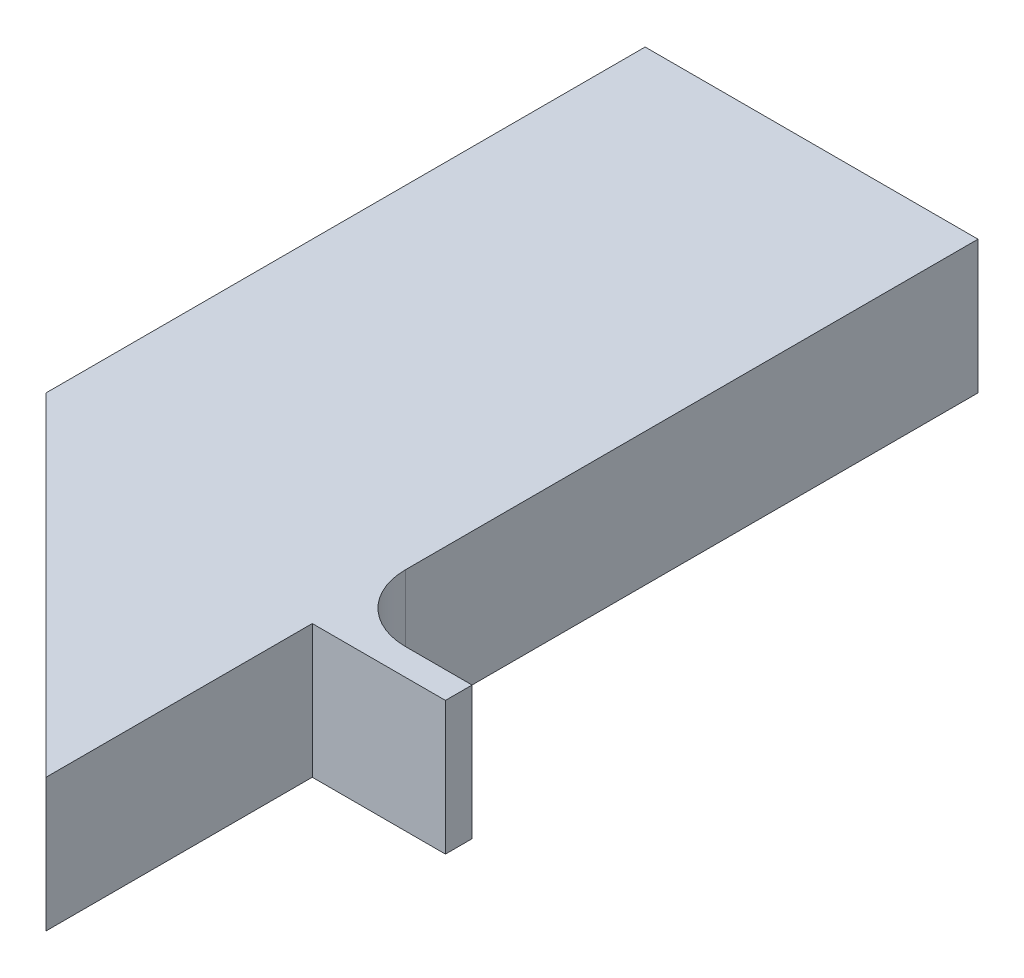
from build123d import *

# Parameters (mm, degrees)
BOSS_EXTRUDE1_DEPTH = 20
SKETCH2_W           = 4
SKETCH2_H           = 20
BOSS_EXTRUDE2_DEPTH = 20
SKETCH3_W           = 46
SKETCH3_H           = 12
CUT_EXTRUDE1_DEPTH  = 46
SKETCH4_R           = 11
CUT_EXTRUDE2_DEPTH  = 8
FILLET1_R           = 10


with BuildPart() as part:
    # Sketch1 → Boss-Extrude1 (new body)
    with BuildSketch(Plane(origin=(0, 0, 0), x_dir=(1, 0, 0), z_dir=(0, 1, 0))):
        Polygon((-50, 50), (0, 0), (0, 140), (-50, 140), align=None)
    extrude(amount=BOSS_EXTRUDE1_DEPTH)

    # Sketch2 → Boss-Extrude2 (add)
    with BuildSketch(Plane(origin=(0, 0, 0), x_dir=(0, 0, -1), z_dir=(1, 0, 0))):
        with Locations((42, 10)):
            Rectangle(SKETCH2_W, SKETCH2_H)
    extrude(amount=BOSS_EXTRUDE2_DEPTH)

    # Sketch3 → Cut-Extrude1 (cut)
    with BuildSketch(Plane.ZY.offset(50)):
        with Locations((-23, 10)):
            Rectangle(SKETCH3_W, SKETCH3_H)
    extrude(amount=-CUT_EXTRUDE1_DEPTH, mode=Mode.SUBTRACT)

    # Sketch4 → Cut-Extrude2 (cut)
    with BuildSketch(Plane.XZ):
        with Locations((-25, -54)):
            Circle(SKETCH4_R)
        with Locations((-25, -114)):
            Circle(SKETCH4_R)
    extrude(amount=-CUT_EXTRUDE2_DEPTH, mode=Mode.SUBTRACT)

    # Fillet1
    fillet1_edges = [part.edges().sort_by_distance(p)[0] for p in [
        (0, 10, -44),
    ]]
    fillet(fillet1_edges, radius=FILLET1_R)


solid = part.part
